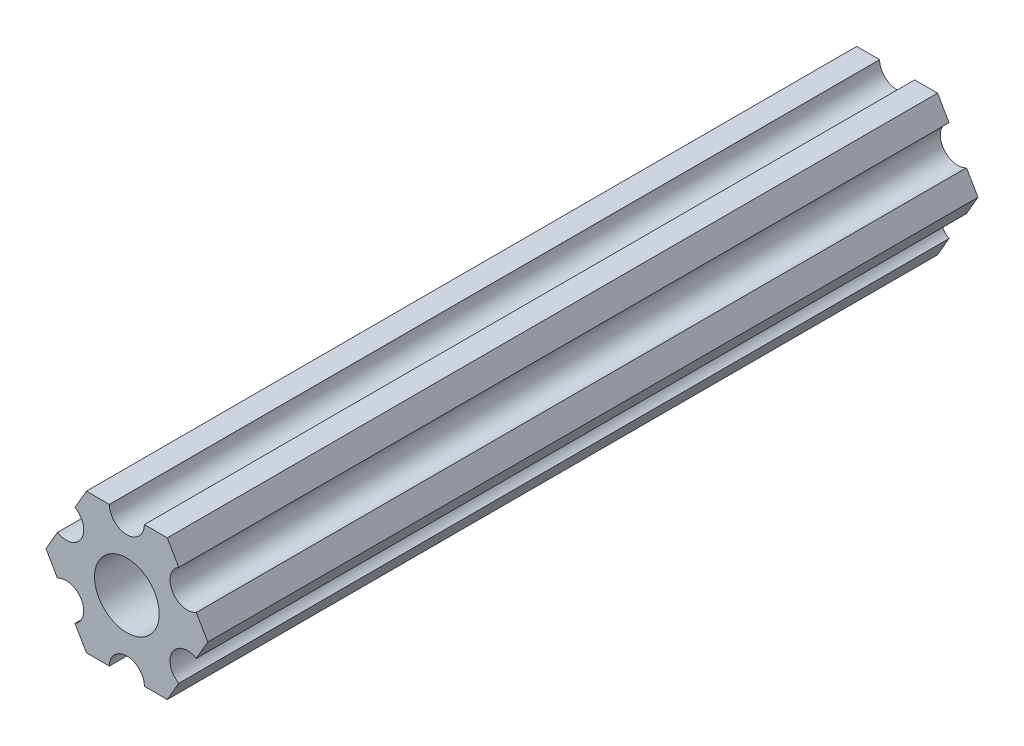
from build123d import *

# Parameters (mm, degrees)
SKETCH1_R           = 2.9337
BOSS_EXTRUDE1_DEPTH = 69.85


with BuildPart() as part:
    # Sketch1 → Boss-Extrude1 (new body)
    with BuildSketch(Plane(origin=(0, 0, 0), x_dir=(-1, 0, 0), z_dir=(0, 0, -1))):
        with BuildLine():
            Line((-4.70551159, -4.549815043), (-3.666174521, -6.349999904))
            Line((-3.666174521, -6.349999904), (-1.587500385, -6.349999904))
            ThreePointArc((-1.587500385, -6.349999904), (-3.85e-07, -4.762499904), (1.587499615, -6.349999904))
            Line((1.587499615, -6.349999904), (3.666173825, -6.349999904))
            Line((3.666173825, -6.349999904), (4.705510942, -4.54981524))
            ThreePointArc((4.705510942, -4.54981524), (4.124445629, -2.381249907), (6.293010962, -1.800184594))
            Line((6.293010962, -1.800184594), (7.332348079, 7e-08))
            Line((7.332348079, 7e-08), (6.293011217, 1.800184685))
            ThreePointArc((6.293011217, 1.800184685), (4.124445939, 2.381250203), (4.705511457, 4.549815481))
            Line((4.705511457, 4.549815481), (3.666174521, 6.350000222))
            Line((3.666174521, 6.350000222), (1.587500385, 6.350000222))
            ThreePointArc((1.587500385, 6.350000222), (3.85e-07, 4.762500222), (-1.587499615, 6.350000222))
            Line((-1.587499615, 6.350000222), (-3.666173825, 6.350000222))
            Line((-3.666173825, 6.350000222), (-4.705511038, 4.549815614))
            ThreePointArc((-4.705511038, 4.549815614), (-4.124445841, 2.38125025), (-6.293011205, 1.800185053))
            Line((-6.293011205, 1.800185053), (-7.332348419, 4.44e-07))
            Line((-7.332348419, 4.44e-07), (-6.293011423, -1.80018429))
            ThreePointArc((-6.293011423, -1.80018429), (-4.12444613, -2.38124975), (-4.70551159, -4.549815043))
        make_face()
        Circle(SKETCH1_R, mode=Mode.SUBTRACT)
    extrude(amount=BOSS_EXTRUDE1_DEPTH)


solid = part.part
